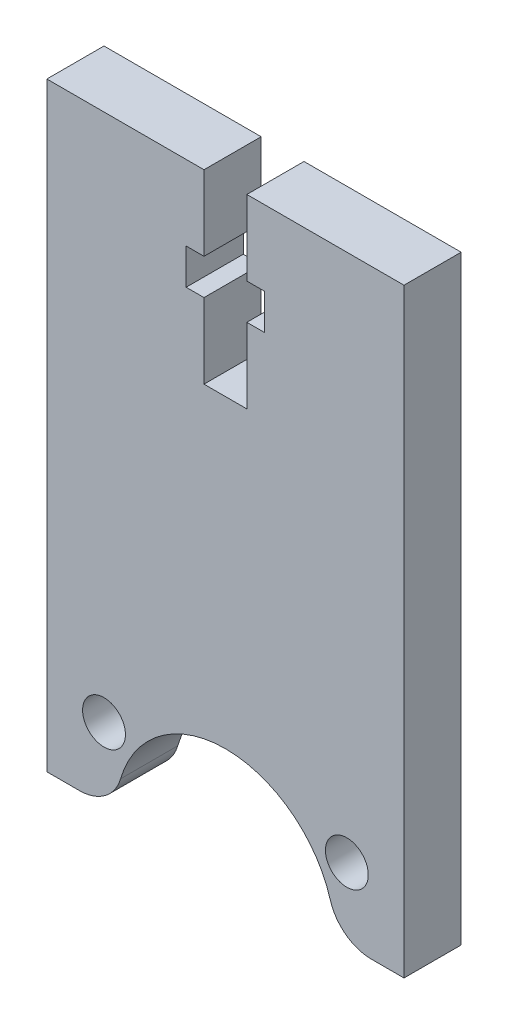
from build123d import *

# Parameters (mm, degrees)
SKETCH_1_R      = 1.5
EXTRUDE_1_DEPTH = 4


with BuildPart() as part:
    # Эскиз1 → Бобышка-Вытянуть1 (new body)
    with BuildSketch(Plane.XY):
        with BuildLine():
            Line((11, 42), (11, 36.75))
            Line((11, 36.75), (9.75, 36.75))
            Line((9.75, 36.75), (9.75, 34.25))
            Line((9.75, 34.25), (11, 34.25))
            Line((11, 34.25), (11, 29))
            Line((11, 29), (14, 29))
            Line((14, 29), (14, 34.25))
            Line((14, 34.25), (15.25, 34.25))
            Line((15.25, 34.25), (15.25, 36.75))
            Line((15.25, 36.75), (14, 36.75))
            Line((14, 36.75), (14, 42))
            Line((14, 42), (25, 42))
            Line((25, 42), (25, 0))
            Line((25, 0), (22.718732798, 0))
            ThreePointArc((22.718732798, 0), (20.920846715, 0.598416016), (19.840216517, 2.154929577))
            ThreePointArc((19.840216517, 2.154929577), (12.5, 7.65), (5.159783483, 2.154929577))
            ThreePointArc((5.159783483, 2.154929577), (4.079153285, 0.598416016), (2.281267202, 0))
            Line((2.281267202, 0), (0, 0))
            Line((0, 0), (0, 42))
            Line((0, 42), (11, 42))
        make_face()
        with Locations((4, 5)):
            Circle(SKETCH_1_R, mode=Mode.SUBTRACT)
        with Locations((21, 5)):
            Circle(SKETCH_1_R, mode=Mode.SUBTRACT)
    extrude(amount=EXTRUDE_1_DEPTH)


solid = part.part
